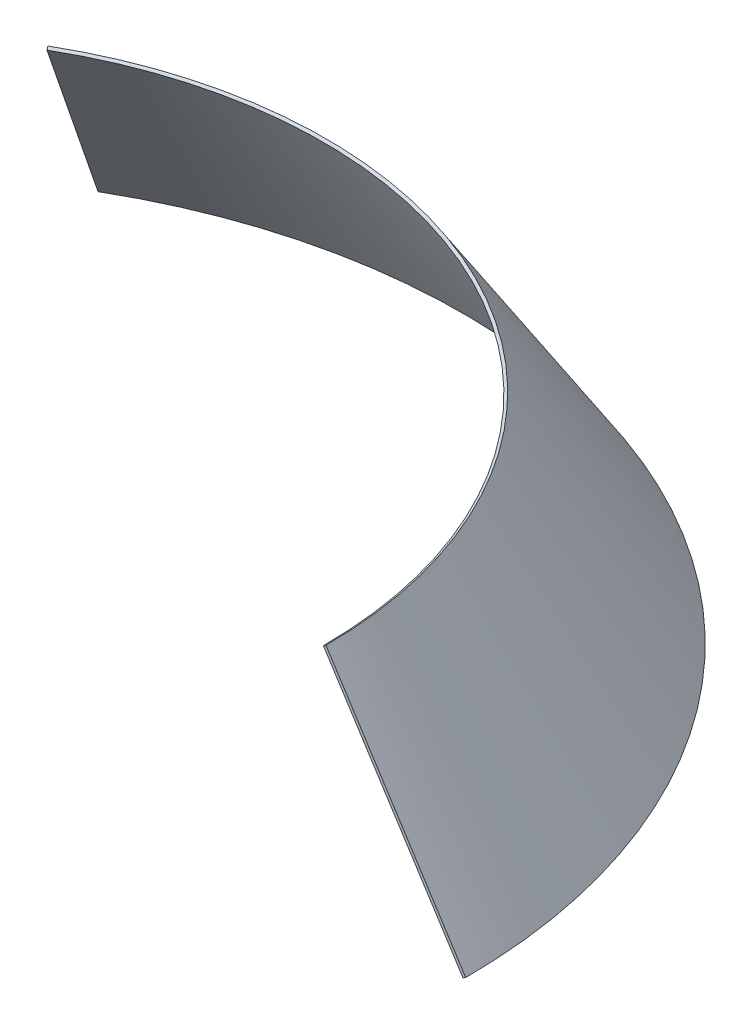
from build123d import *

# Parameters (mm, degrees)
ROTACE_TENKOST_NN_2_ANGLE = 120


with BuildPart() as part:
    # Skica6 → Rotace tenkostěnný2 (revolve)
    with BuildSketch(Plane.XY):
        Polygon((90.536810265, 0), (68.570502201, 34.2852511), (68.991505454, 34.554984786), (90.957813518, 0.269733686), align=None)
    revolve(axis=Axis((0, 0, 0), (0, 1, 0)), revolution_arc=ROTACE_TENKOST_NN_2_ANGLE)


solid = part.part
